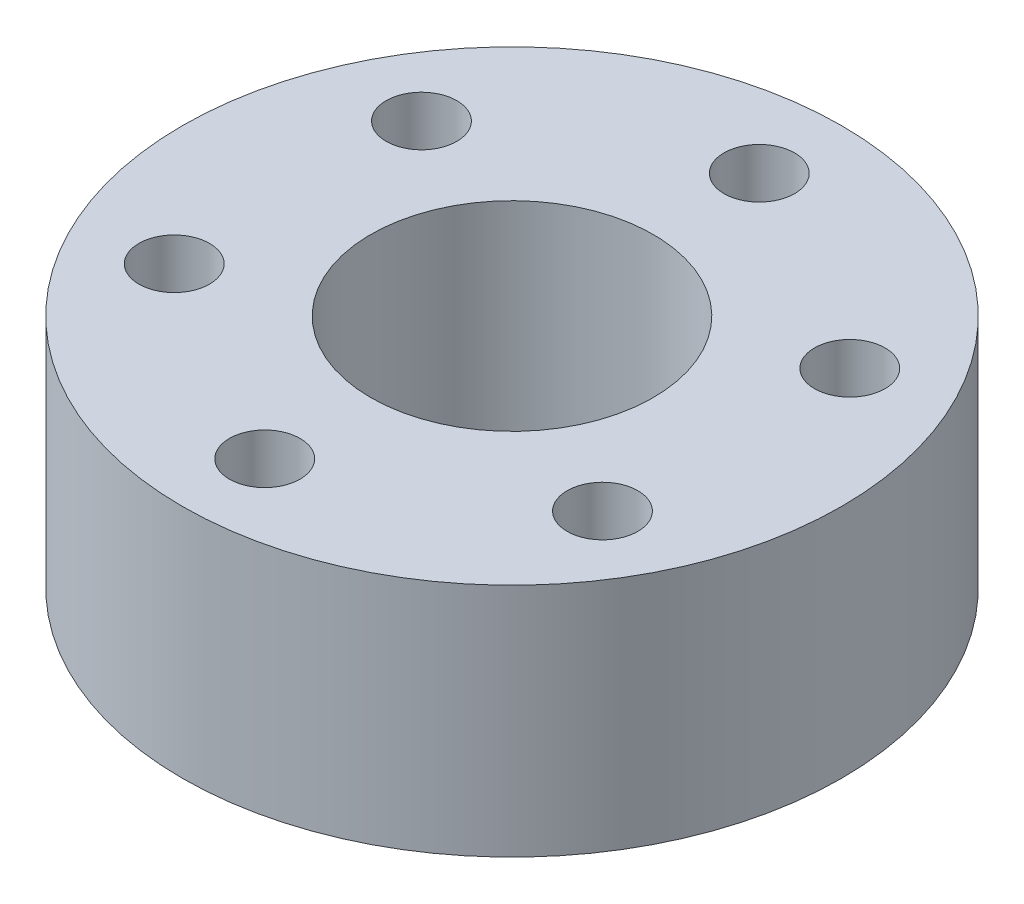
from build123d import *

# Parameters (mm, degrees)
SKETCH1_R           = 14
BOSS_EXTRUDE1_DEPTH = 10
SKETCH2_R           = 1.5
SKETCH2_R_2         = 6
CUT_EXTRUDE1_DEPTH  = 11
SCALE_1_SCALE       = 0.894736842


with BuildPart() as part:
    # Sketch1 → Boss-Extrude1 (new body)
    with BuildSketch(Plane(origin=(0, 0, 0), x_dir=(1, 0, 0), z_dir=(0, 1, 0))):
        Circle(SKETCH1_R)
    extrude(amount=BOSS_EXTRUDE1_DEPTH)

    # Sketch2 → Cut-Extrude1 (cut, through all)
    with BuildSketch(Plane(origin=(0, 10, 0), x_dir=(1, 0, 0), z_dir=(0, 1, 0))):
        with Locations((0, 10.5)):
            Circle(SKETCH2_R)
        Circle(SKETCH2_R_2)
        with Locations((9.09326674, 5.25)):
            Circle(SKETCH2_R)
        with Locations((9.09326674, -5.25)):
            Circle(SKETCH2_R)
        with Locations((0, -10.5)):
            Circle(SKETCH2_R)
        with Locations((-9.09326674, -5.25)):
            Circle(SKETCH2_R)
        with Locations((-9.09326674, 5.25)):
            Circle(SKETCH2_R)
    extrude(amount=-CUT_EXTRUDE1_DEPTH, mode=Mode.SUBTRACT)


with BuildPart() as part_1:
    # ｽｹｰﾙ1: scaled about (0, 5, 0)
    add(part.part.scale(SCALE_1_SCALE).moved(Location((0, 0.526315789, 0))))


solid = part_1.part
